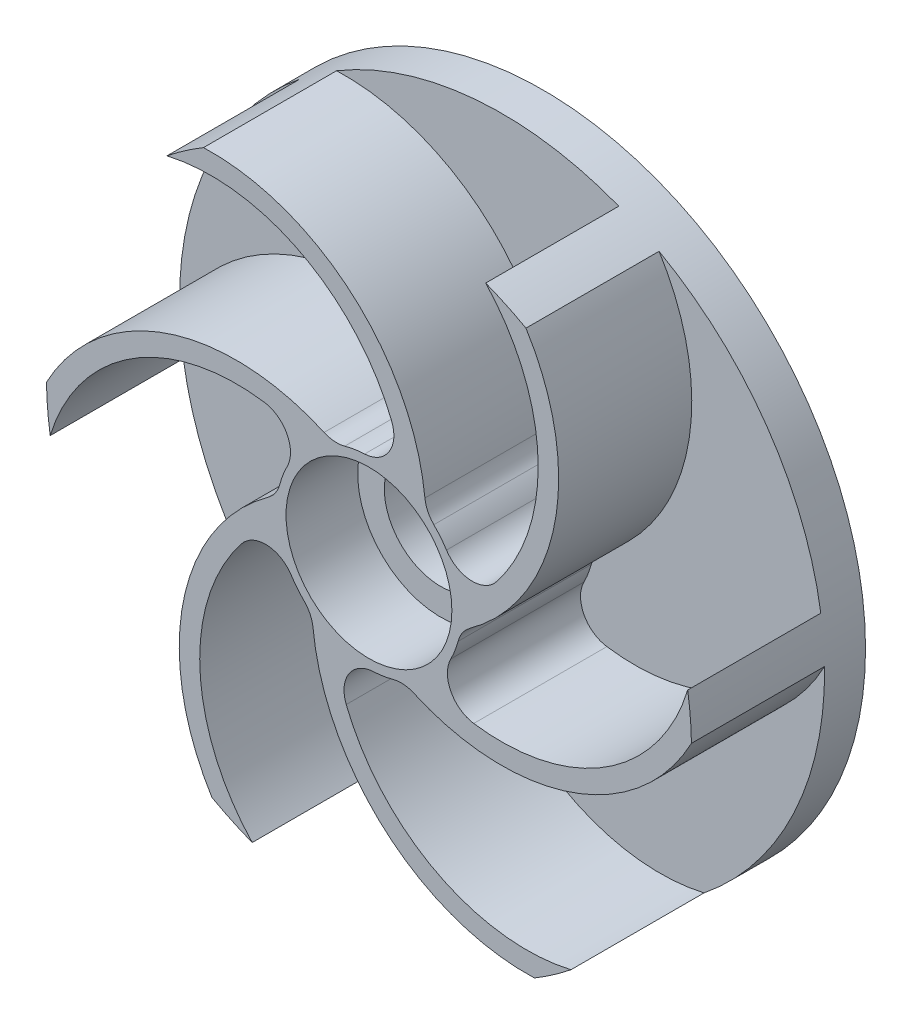
from build123d import *

# Parameters (mm, degrees)
SKETCH1_R                     = 31.5
EXTRUDE1_DEPTH                = 4
SKETCH3_R                     = 9
EXTRUDE2_DEPTH                = 6
M11_0_11_DIAMETER_HOLE1_D     = 11
M11_0_11_DIAMETER_HOLE1_DEPTH = 10
M11_0_11_DIAMETER_HOLE1_TIP   = 3.304733405
EXTRUDE4_DEPTH                = 13
CIRPATTERN2_COUNT             = 6
SKETCH7_R                     = 9
SKETCH7_R_2                   = 8.1
EXTRUDE5_DEPTH                = 17


with BuildPart() as part:
    # Sketch1 → Extrude1 (new body)
    with BuildSketch(Plane.XY):
        Circle(SKETCH1_R)
    extrude(amount=EXTRUDE1_DEPTH)

    # Sketch3 → Extrude2 (add)
    with BuildSketch(Plane.XY.offset(4)):
        Circle(SKETCH3_R)
    extrude(amount=EXTRUDE2_DEPTH)

    # M11.0 _11_ Diameter Hole1
    with Locations(Plane.XY.offset(10)):
        with Locations((0, 0)):
            Hole(M11_0_11_DIAMETER_HOLE1_D / 2, depth=M11_0_11_DIAMETER_HOLE1_DEPTH)
            with Locations((0, 0, -(M11_0_11_DIAMETER_HOLE1_DEPTH + M11_0_11_DIAMETER_HOLE1_TIP / 2))):  # 118° drill point
                Cone(0, M11_0_11_DIAMETER_HOLE1_D / 2, M11_0_11_DIAMETER_HOLE1_TIP, mode=Mode.SUBTRACT)

    # Sketch2_8 → Extrude4 (add)
    with BuildSketch(Plane.XY.offset(4)):
        with BuildLine():
            ThreePointArc((-9.844910533, 0.62593686), (-18.139880625, -12.361871339), (-15.335083755, -27.515181378))
            ThreePointArc((-15.335083755, -27.515181378), (-13.401012303, -28.5072424), (-11.403128973, -29.363559894))
            ThreePointArc((-11.403128973, -29.363559894), (-16.511325203, -17.190045629), (-12.454740571, -4.626915468))
            ThreePointArc((-12.454740571, -4.626915468), (-9.953426801, -3.486629519), (-7.573470906, -4.862359348))
            ThreePointArc((-7.573470906, -4.862359348), (-8.889824652, -1.403929362), (-8.703301392, 2.291843117))
            ThreePointArc((-8.703301392, 2.291843117), (-9.129712004, 1.359939965), (-9.844910533, 0.62593686))
        make_face()
    extrude4 = extrude(amount=EXTRUDE4_DEPTH)

    # CirPattern2: Extrude4 ×6 about axis
    cirpattern2_axis = Axis((0, 0, 0), (0, 0, 1))
    for i in range(1, CIRPATTERN2_COUNT):
        add(extrude4.rotate(cirpattern2_axis, i * 360 / CIRPATTERN2_COUNT))

    # Sketch7 → Extrude5 (add)
    with BuildSketch(Plane(origin=(0, 0, 0), x_dir=(-1, 0, 0), z_dir=(0, 0, -1))):
        Circle(SKETCH7_R)
        with Locations(Location((0, 0, 0), (0, 0, 180))):  # turned: the seam where the file's is
            Circle(SKETCH7_R_2, mode=Mode.SUBTRACT)
    extrude(amount=-EXTRUDE5_DEPTH)


solid = part.part
